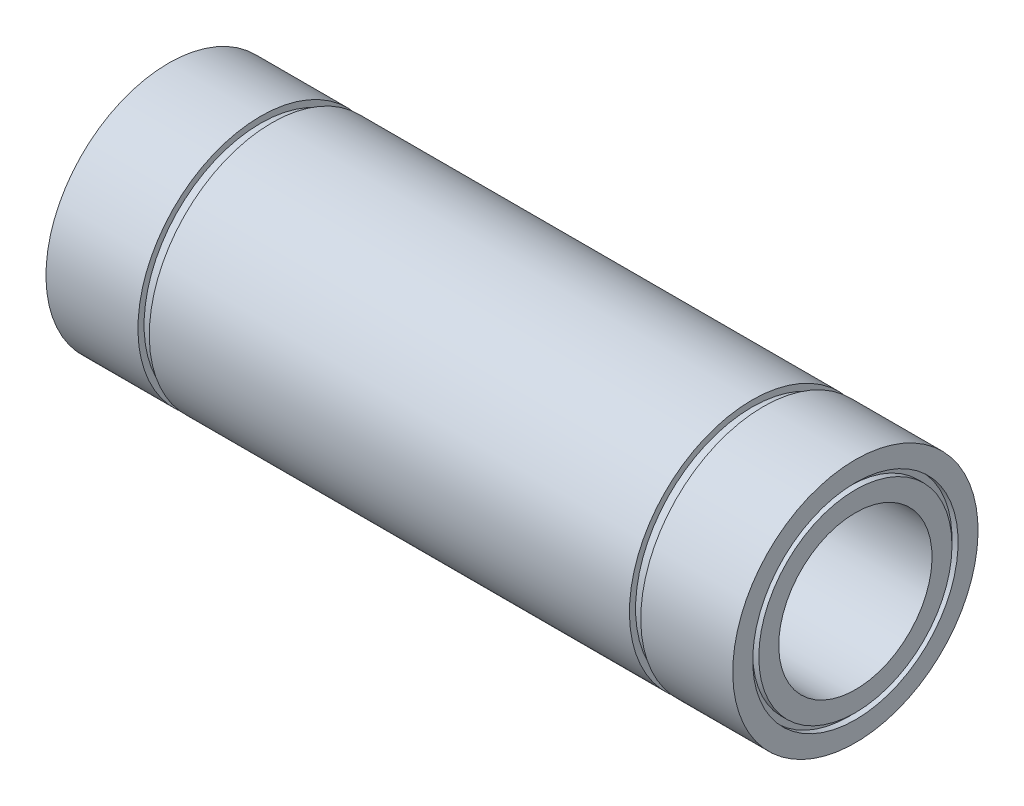
from build123d import *


with BuildPart() as part:
    # Esboço1 → Revolução1 (revolve)
    with BuildSketch(Plane.XY):
        Polygon((-56, 20), (-41, 20), (-41, 19), (-39.15, 19), (-39.15, 20), (39.15, 20), (39.15, 19), (41, 19), (41, 20), (56, 20), (56, 16.75), (55, 16.75), (55, 15.75), (56, 15.75), (56, 12.5), (-56, 12.5), (-56, 15.75), (-55, 15.75), (-55, 16.75), (-56, 16.75), align=None)
    revolve(axis=Axis((0, 0, 0), (-1, 0, 0)))


solid = part.part
